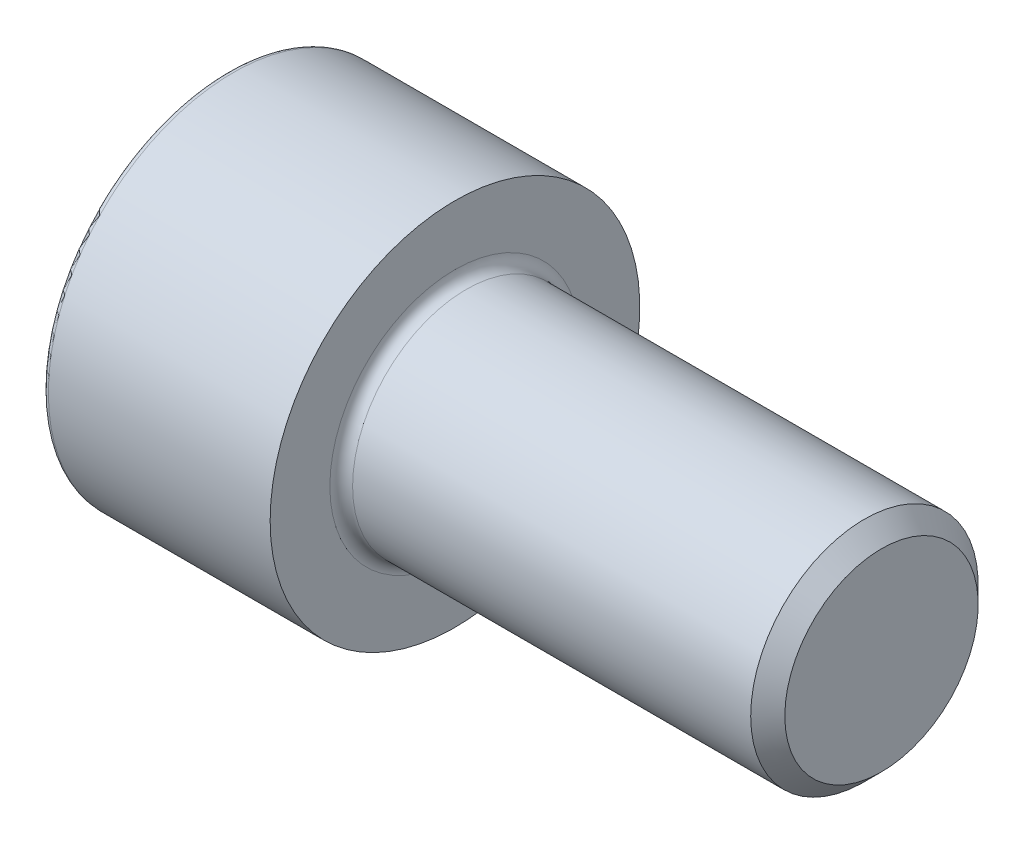
from build123d import *

# Parameters (mm, degrees)
MM_1_D              = 6
MM_1_DEPTH          = 4
MM_1_TIP            = 1.802581857
CUT_EXTRUDE_1_DEPTH = 4
FILLET_1_R          = 0.2
CHAMFER_1_SIZE      = 0.6
FILLET_2_R          = 0.4


with BuildPart() as part:
    # 草图1 → 旋转1 (revolve)
    with BuildSketch(Plane.XY):
        Polygon((0, 0), (0, 6.5), (8, 6.5), (8, 4), (23, 4), (23, 0), align=None)
    revolve(axis=Axis((0, 0, 0), (1, 0, 0)))

    # 大小mm 暗销孔1
    with Locations(Plane.ZY):
        with Locations((0, 0)):
            Hole(MM_1_D / 2, depth=MM_1_DEPTH)
            with Locations((0, 0, -(MM_1_DEPTH + MM_1_TIP / 2))):  # 118° drill point
                Cone(0, MM_1_D / 2, MM_1_TIP, mode=Mode.SUBTRACT)

    # 草图4 → 切除-拉伸1 (cut)
    with BuildSketch(Plane.ZY):
        Polygon((3, 1.732050808), (0, 3.464101615), (-3, 1.732050808), (-3, -1.732050808), (0, -3.464101615), (3, -1.732050808), align=None)
    extrude(amount=-CUT_EXTRUDE_1_DEPTH, mode=Mode.SUBTRACT)

    # 圆角1
    fillet_1_edges = [part.edges().sort_by_distance(p)[0] for p in [
        (0, -6.5, 0),
    ]]
    fillet(fillet_1_edges, radius=FILLET_1_R)

    # 倒角1
    chamfer_1_edges = [part.edges().sort_by_distance(p)[0] for p in [
        (23, -4, 0),
    ]]
    chamfer(chamfer_1_edges, length=CHAMFER_1_SIZE)

    # 圆角2
    fillet_2_edges = [part.edges().sort_by_distance(p)[0] for p in [
        (8, -4, 0),
    ]]
    fillet(fillet_2_edges, radius=FILLET_2_R)


solid = part.part
